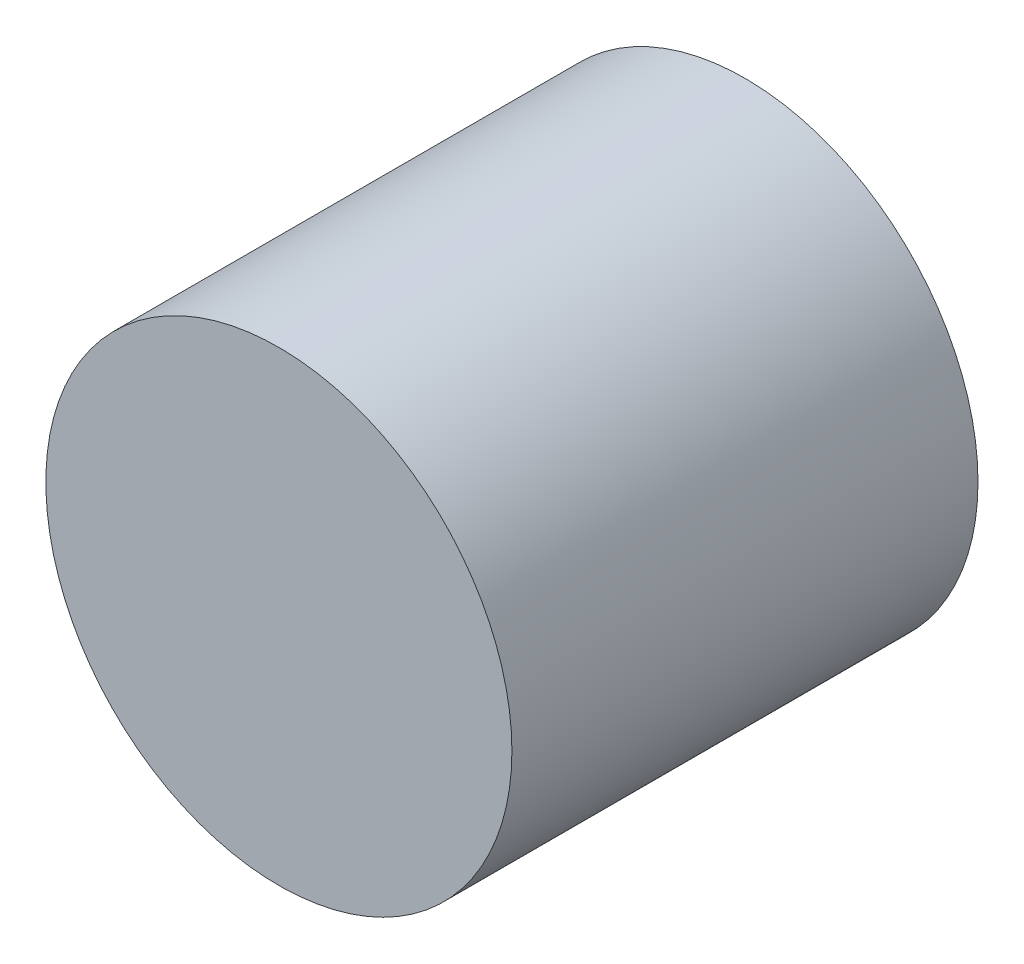
from build123d import *

# Parameters (mm, degrees)
SKETCH1_R           = 3.2
BOSS_EXTRUDE1_DEPTH = 6.4


with BuildPart() as part:
    # Sketch1 → Boss-Extrude1 (new body)
    with BuildSketch(Plane.XY):
        Circle(SKETCH1_R)
    extrude(amount=BOSS_EXTRUDE1_DEPTH)


solid = part.part
